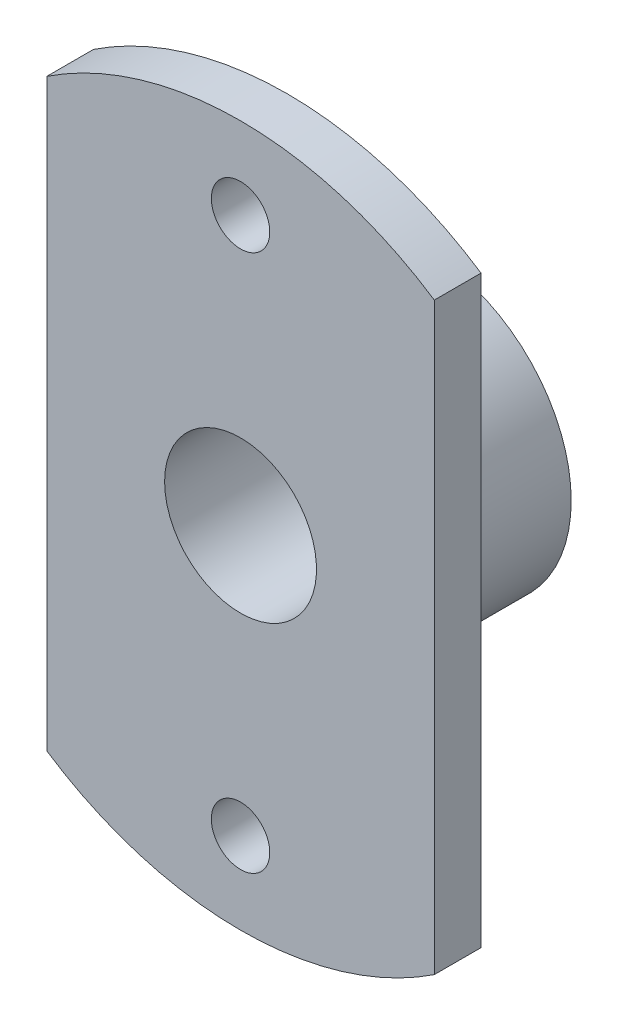
from build123d import *

# Parameters (mm, degrees)
SKETCH1_R           = 12.3
BOSS_EXTRUDE1_DEPTH = 12
SKETCH2_R           = 30
BOSS_EXTRUDE2_DEPTH = 4
SKETCH3_R           = 2.5
CUT_EXTRUDE1_DEPTH  = 5
SKETCH4_R           = 6.5
CUT_EXTRUDE2_DEPTH  = 17
CUT_EXTRUDE3_DEPTH  = 5


with BuildPart() as part:
    # Sketch1 → Boss-Extrude1 (new body)
    with BuildSketch(Plane(origin=(0, 0, 0), x_dir=(0, 1, 0), z_dir=(0, 0, 1))):
        Circle(SKETCH1_R)
    extrude(amount=BOSS_EXTRUDE1_DEPTH)

    # Sketch2 → Boss-Extrude2 (add)
    with BuildSketch(Plane.XY.offset(12)):
        Circle(SKETCH2_R)
    extrude(amount=BOSS_EXTRUDE2_DEPTH)

    # Sketch3 → Cut-Extrude1 (cut, through all)
    with BuildSketch(Plane(origin=(0, 0, 12), x_dir=(1, 0, 0), z_dir=(0, 0, -1))):
        with Locations((0, 23)):
            Circle(SKETCH3_R)
        with Locations((0, -23)):
            Circle(SKETCH3_R)
    extrude(amount=-CUT_EXTRUDE1_DEPTH, mode=Mode.SUBTRACT)

    # Sketch4 → Cut-Extrude2 (cut, through all)
    with BuildSketch(Plane(origin=(0, 0, 0), x_dir=(1, 0, 0), z_dir=(0, 0, -1))):
        Circle(SKETCH4_R)
    extrude(amount=-CUT_EXTRUDE2_DEPTH, mode=Mode.SUBTRACT)

    # Sketch5 → Cut-Extrude3 (cut, through all)
    with BuildSketch(Plane(origin=(0, 0, 12), x_dir=(1, 0, 0), z_dir=(0, 0, -1))):
        with BuildLine():
            Line((-16.583123952, -25), (-16.583123952, 25))
            ThreePointArc((-16.583123952, 25), (-30, 0), (-16.583123952, -25))
        make_face()
        with BuildLine():
            Line((16.583123952, -25), (16.583123952, 25))
            ThreePointArc((16.583123952, 25), (30, 0), (16.583123952, -25))
        make_face()
    extrude(amount=-CUT_EXTRUDE3_DEPTH, mode=Mode.SUBTRACT)


solid = part.part
